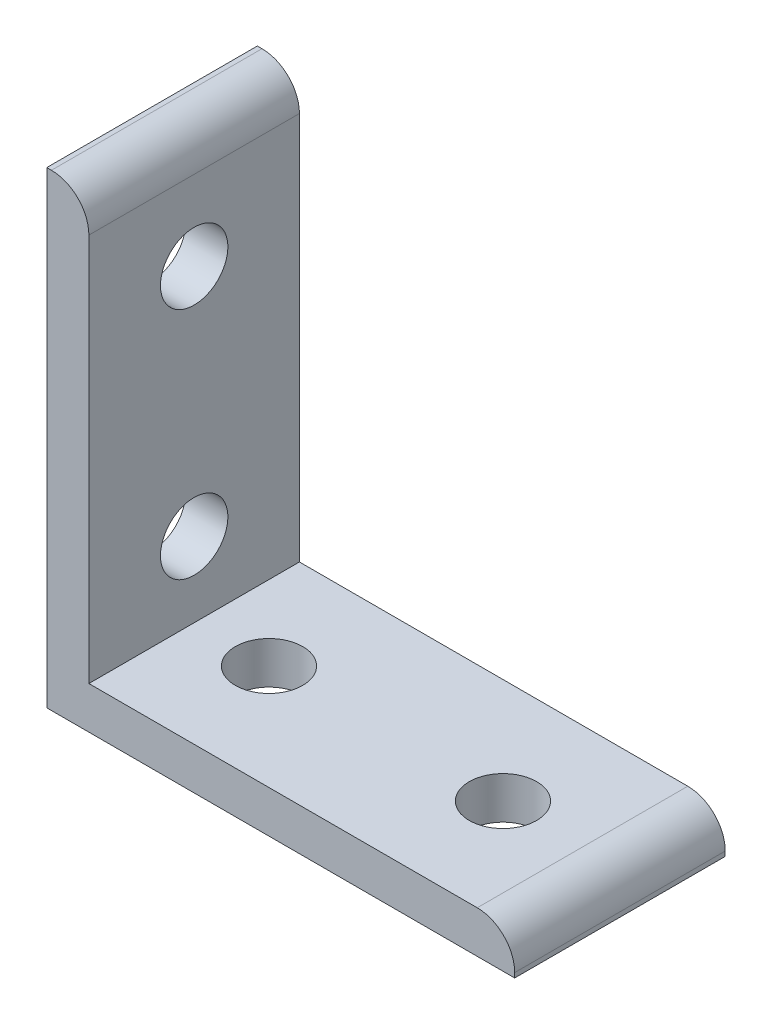
from build123d import *

# Parameters (mm, degrees)
BOSS_EXTRUDE1_DEPTH = 22.5
SKETCH2_R           = 3.6
CUT_EXTRUDE1_DEPTH  = 51
SKETCH3_R           = 3.6
CUT_EXTRUDE2_DEPTH  = 51
FILLET1_R           = 4


with BuildPart() as part:
    # Sketch1 → Boss-Extrude1 (new body)
    with BuildSketch(Plane.XY):
        Polygon((0, 50), (0, 0), (50, 0), (50, 4.5), (4.5, 4.5), (4.5, 50), align=None)
    extrude(amount=BOSS_EXTRUDE1_DEPTH)

    # Sketch2 → Cut-Extrude1 (cut, through all)
    with BuildSketch(Plane.ZY):
        with Locations((11.25, 37.5)):
            Circle(SKETCH2_R)
        with Locations((11.25, 12.5)):
            Circle(SKETCH2_R)
    extrude(amount=-CUT_EXTRUDE1_DEPTH, mode=Mode.SUBTRACT)

    # Sketch3 → Cut-Extrude2 (cut, through all)
    with BuildSketch(Plane.XZ):
        with Locations((37.5, 11.25)):
            Circle(SKETCH3_R)
        with Locations((12.5, 11.25)):
            Circle(SKETCH3_R)
    extrude(amount=-CUT_EXTRUDE2_DEPTH, mode=Mode.SUBTRACT)

    # Fillet1
    fillet1_edges = [part.edges().sort_by_distance(p)[0] for p in [
        (4.5, 50, 11.25),
        (50, 4.5, 11.25),
    ]]
    fillet(fillet1_edges, radius=FILLET1_R)


solid = part.part
